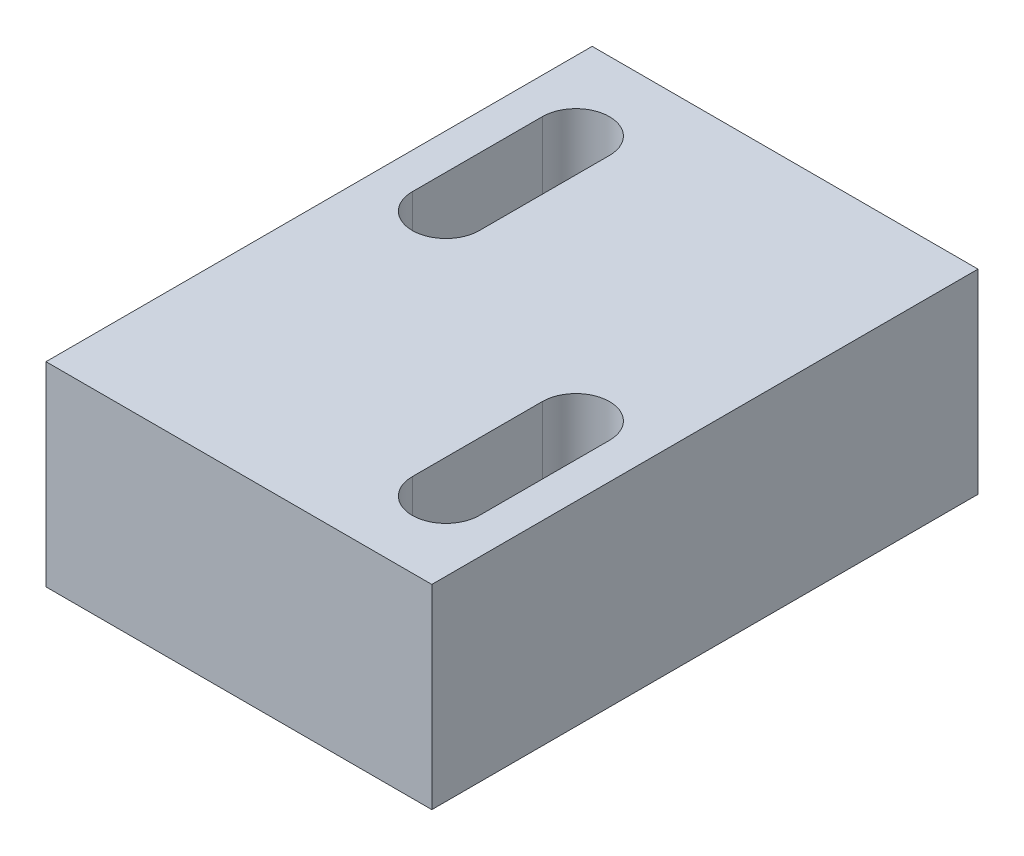
from build123d import *

# Parameters (mm, degrees)
CROQUIS1_W              = 35
CROQUIS1_H              = 25.2
SALIENTE_EXTRUIR1_DEPTH = 9
CORTAR_EXTRUIR1_DEPTH   = 10
CROQUIS3_W              = 17.198072292
CROQUIS3_H              = 25.2
CORTAR_EXTRUIR2_DEPTH   = 10


with BuildPart() as part:
    # Croquis1 → Saliente-Extruir1 (new body)
    with BuildSketch(Plane(origin=(0, 0, 0), x_dir=(1, 0, 0), z_dir=(0, 1, 0))):
        Rectangle(CROQUIS1_W, CROQUIS1_H)
    extrude(amount=SALIENTE_EXTRUIR1_DEPTH)

    # Croquis2 → Cortar-Extruir1 (cut, through all)
    with BuildSketch(Plane.XZ):
        with BuildLine():
            Line((-4.457181896, 2.743708499), (-4.457181896, 8.743708499))
            ThreePointArc((-4.457181896, 8.743708499), (-2.907181896, 10.293708499), (-1.357181896, 8.743708499))
            Line((-1.357181896, 8.743708499), (-1.357181896, 2.743708499))
            ThreePointArc((-1.357181896, 2.743708499), (-2.907181896, 1.193708499), (-4.457181896, 2.743708499))
        make_face()
        with BuildLine():
            Line((-12.740890395, -8.64), (-12.740890395, -2.64))
            ThreePointArc((-12.740890395, -2.64), (-14.290890395, -1.09), (-15.840890395, -2.64))
            Line((-15.840890395, -2.64), (-15.840890395, -8.64))
            ThreePointArc((-15.840890395, -8.64), (-14.290890395, -10.19), (-12.740890395, -8.64))
        make_face()
    extrude(amount=-CORTAR_EXTRUIR1_DEPTH, mode=Mode.SUBTRACT)

    # Croquis3 → Cortar-Extruir2 (cut, through all)
    with BuildSketch(Plane.XZ):
        with Locations((8.900963854, 0)):
            Rectangle(CROQUIS3_W, CROQUIS3_H)
    extrude(amount=-CORTAR_EXTRUIR2_DEPTH, mode=Mode.SUBTRACT)


solid = part.part
